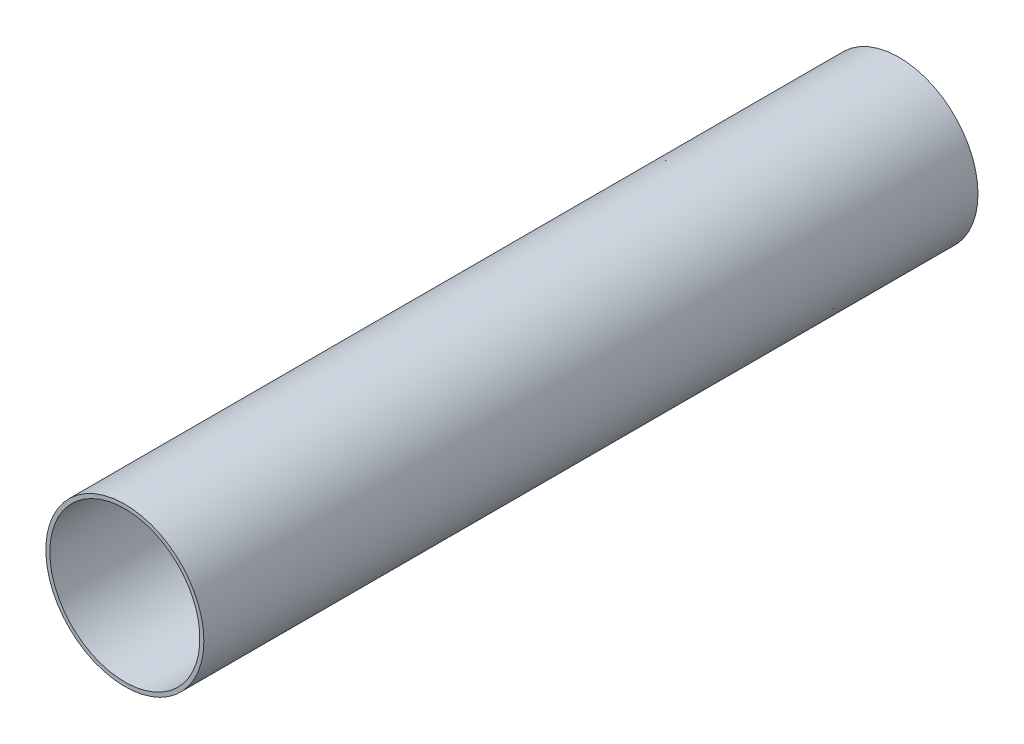
from build123d import *

# Parameters (mm, degrees)
BOSS_EXTRUDE1_DEPTH      = 245
BOSS_EXTRUDE1_DEPTH_BACK = 245
SKETCH1_R                = 50
CUT_EXTRUDE25_DEPTH      = 496.075751779
CUT_EXTRUDE25_DEPTH_BACK = 496.075751779
SKETCH2_R                = 47.5


with BuildPart() as part:
    # Sketch1 → Boss-Extrude1 (new, two sides: drawn at the far end of the back side and taken through both)
    with BuildSketch(Plane.XY.offset(-BOSS_EXTRUDE1_DEPTH_BACK)):
        Circle(SKETCH1_R)
    extrude(amount=BOSS_EXTRUDE1_DEPTH + BOSS_EXTRUDE1_DEPTH_BACK)

    # Sketch2 → Cut-Extrude25 (cut, two sides: drawn at the far end of the back side and taken through both)
    with BuildSketch(Plane(origin=(0, 0, -245), x_dir=(-1, 0, 0), z_dir=(0, 0, -1)).offset(-CUT_EXTRUDE25_DEPTH_BACK)):
        Circle(SKETCH2_R)
    extrude(amount=CUT_EXTRUDE25_DEPTH + CUT_EXTRUDE25_DEPTH_BACK, mode=Mode.SUBTRACT)


solid = part.part
